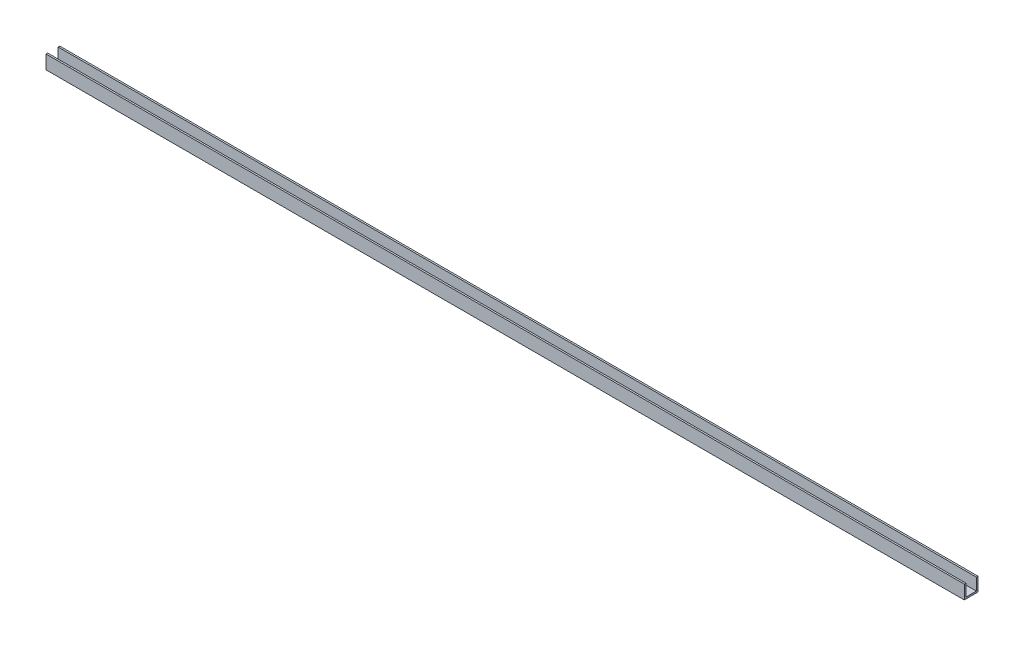
from build123d import *

# Parameters (mm, degrees)
SALIENTE_EXTRUIR1_DEPTH = 835


with BuildPart() as part:
    # Croquis1 → Saliente-Extruir1 (new body)
    with BuildSketch(Plane(origin=(0, 0, 0), x_dir=(0, 0, -1), z_dir=(1, 0, 0))):
        Polygon((-6.25, 6.25), (-6.25, -6.25), (6.25, -6.25), (6.25, 6.25), (4.75, 6.25), (4.75, -4.75), (-4.75, -4.75), (-4.75, 6.25), align=None)
    extrude(amount=SALIENTE_EXTRUIR1_DEPTH)


solid = part.part
